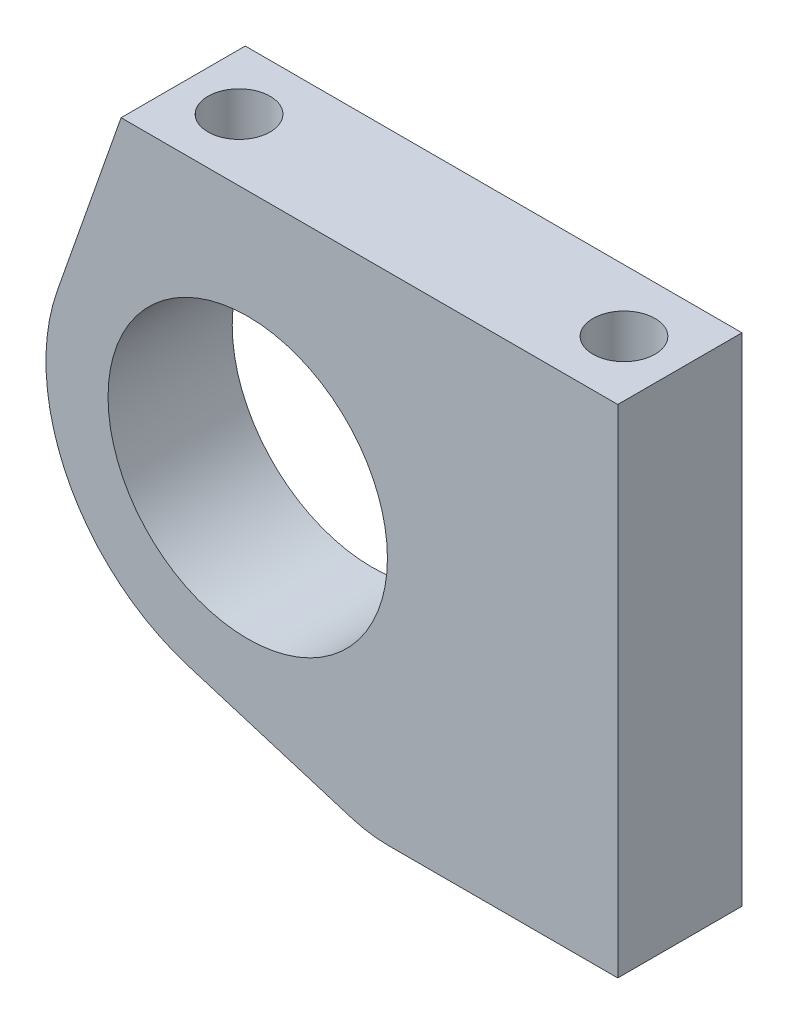
from build123d import *

# Parameters (mm, degrees)
SKETCH1_R           = 14.2875
BOSS_EXTRUDE2_DEPTH = 12.7
SKETCH3_R           = 3.175
CUT_EXTRUDE2_DEPTH  = 12.7


with BuildPart() as part:
    # Sketch1 → Boss-Extrude2 (new body)
    with BuildSketch(Plane.XY):
        with BuildLine():
            Line((50.8, 50.8), (0, 50.8))
            Line((0, 50.8), (-6.517989108, 32.237254305))
            ThreePointArc((-6.517989108, 32.237254305), (-5.465821228, 16.093196457), (6.906112814, 5.668566529))
            Line((6.906112814, 5.668566529), (23.580878621, 0.557579402))
            ThreePointArc((23.580878621, 0.557579402), (25.420999377, 0.140168361), (27.302655351, 0))
            Line((27.302655351, 0), (50.8, 0))
            Line((50.8, 0), (50.8, 50.8))
        make_face()
        with Locations((12.954, 25.4)):
            Circle(SKETCH1_R, mode=Mode.SUBTRACT)
    extrude(amount=BOSS_EXTRUDE2_DEPTH)

    # Sketch3 → Cut-Extrude2 (cut)
    with BuildSketch(Plane(origin=(0, 50.8, 0), x_dir=(1, 0, 0), z_dir=(0, 1, 0))):
        with Locations((45.085, -6.35)):
            Circle(SKETCH3_R)
        with Locations((5.715, -6.35)):
            Circle(SKETCH3_R)
    extrude(amount=-CUT_EXTRUDE2_DEPTH, mode=Mode.SUBTRACT)


solid = part.part
